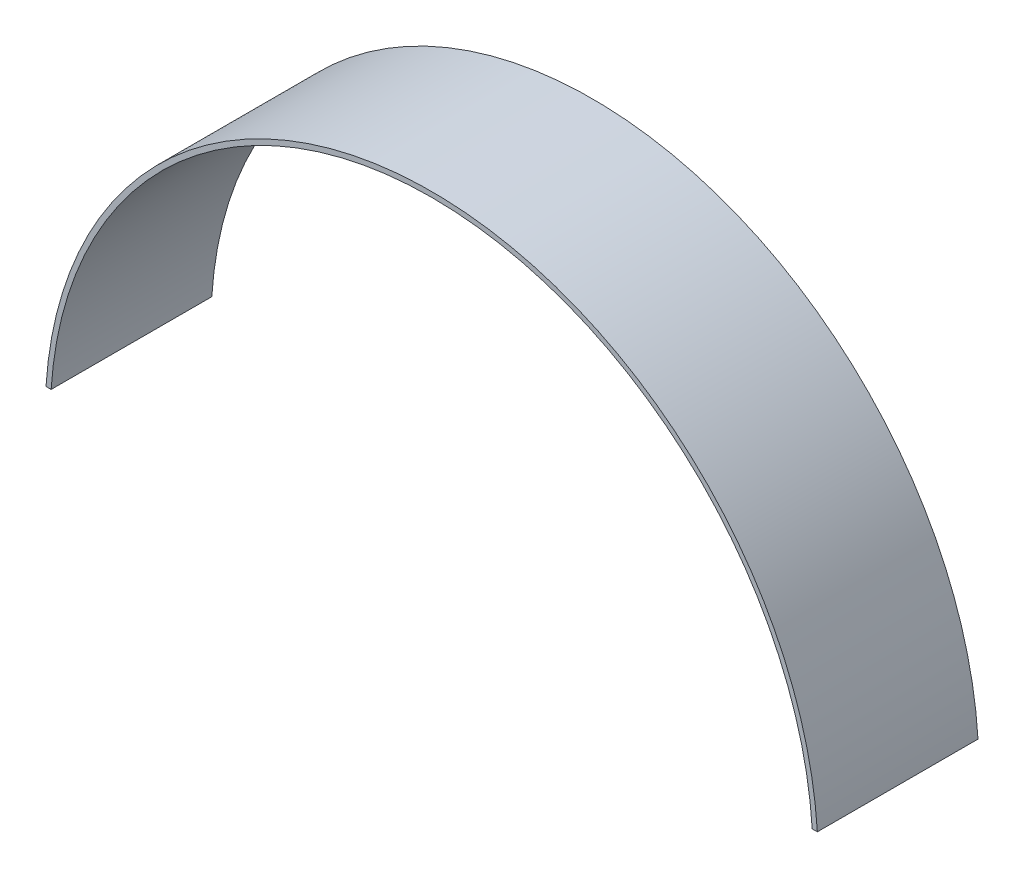
from build123d import *

# Parameters (mm, degrees)
BOSS_EXTRUDE1_DEPTH = 30


with BuildPart() as part:
    # Sketch1 → Boss-Extrude1 (new body)
    with BuildSketch(Plane.XY):
        with BuildLine():
            ThreePointArc((72.018823772, 4.610764133), (0, 72.166267212), (-72.018823772, 4.610764133))
            Line((-72.018823772, 4.610764133), (-71.062529975, 4.610764133))
            ThreePointArc((-71.062529975, 4.610764133), (0, 71.211953437), (71.062529975, 4.610764133))
            Line((71.062529975, 4.610764133), (72.018823772, 4.610764133))
        make_face()
    extrude(amount=BOSS_EXTRUDE1_DEPTH)


solid = part.part
